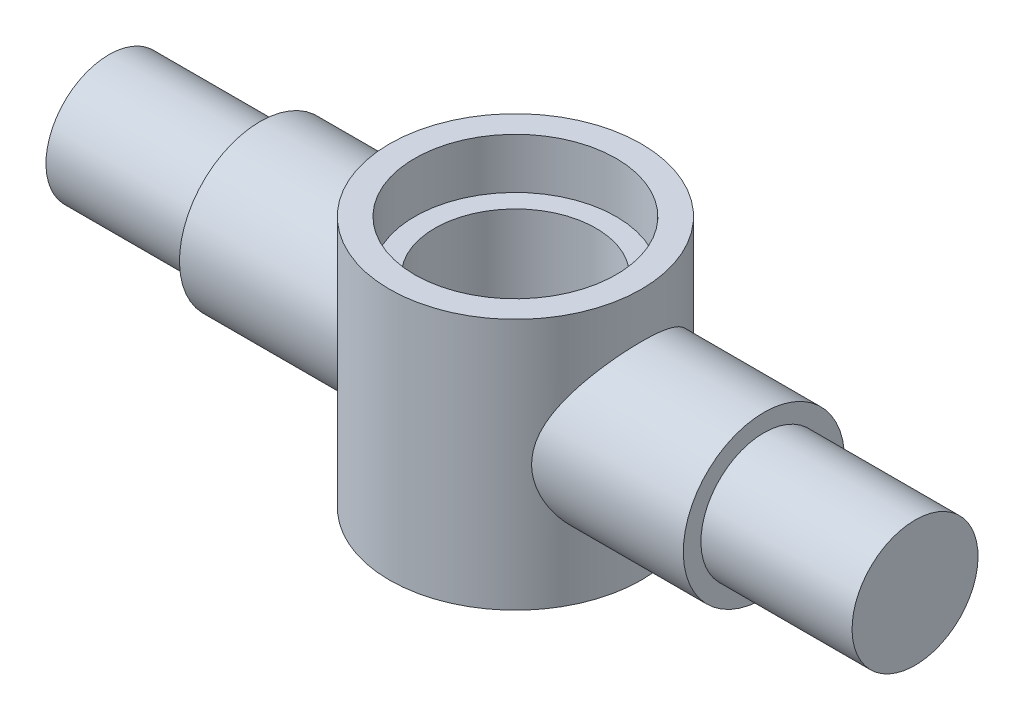
from build123d import *

# Parameters (mm, degrees)
SKETCH1_W                               = 25
SKETCH1_H                               = 50
CBORE_FOR_M5_HEX_HEAD_BOLT1_D           = 32
CBORE_FOR_M5_HEX_HEAD_BOLT1_CBORE_D     = 40
CBORE_FOR_M5_HEX_HEAD_BOLT1_CBORE_DEPTH = 10


with BuildPart() as part:
    # Sketch1 → Revolve1 (revolve)
    with BuildSketch(Plane.XY):
        with Locations((12.5, 25)):
            Rectangle(SKETCH1_W, SKETCH1_H)
    revolve(axis=Axis((25, 50, 0), (0, -1, 0)))

    # Sketch2 → Revolve2 (revolve)
    with BuildSketch(Plane.XY):
        Polygon((-55.678230708, 25), (-55.678230708, 37.5), (-25.678230708, 37.5), (-25.678230708, 41), (74.321769292, 41), (74.321769292, 37.5), (104.321769292, 37.5), (104.321769292, 25), align=None)
    revolve(axis=Axis((104.321769292, 25, 0), (-1, 0, 0)))

    # CBORE for M5 Hex Head Bolt1 (through all)
    with Locations(Plane(origin=(0, 50, 0), x_dir=(1, 0, 0), z_dir=(0, 1, 0))):
        with Locations((25, 0)):
            CounterBoreHole(CBORE_FOR_M5_HEX_HEAD_BOLT1_D / 2, CBORE_FOR_M5_HEX_HEAD_BOLT1_CBORE_D / 2, CBORE_FOR_M5_HEX_HEAD_BOLT1_CBORE_DEPTH)


solid = part.part
